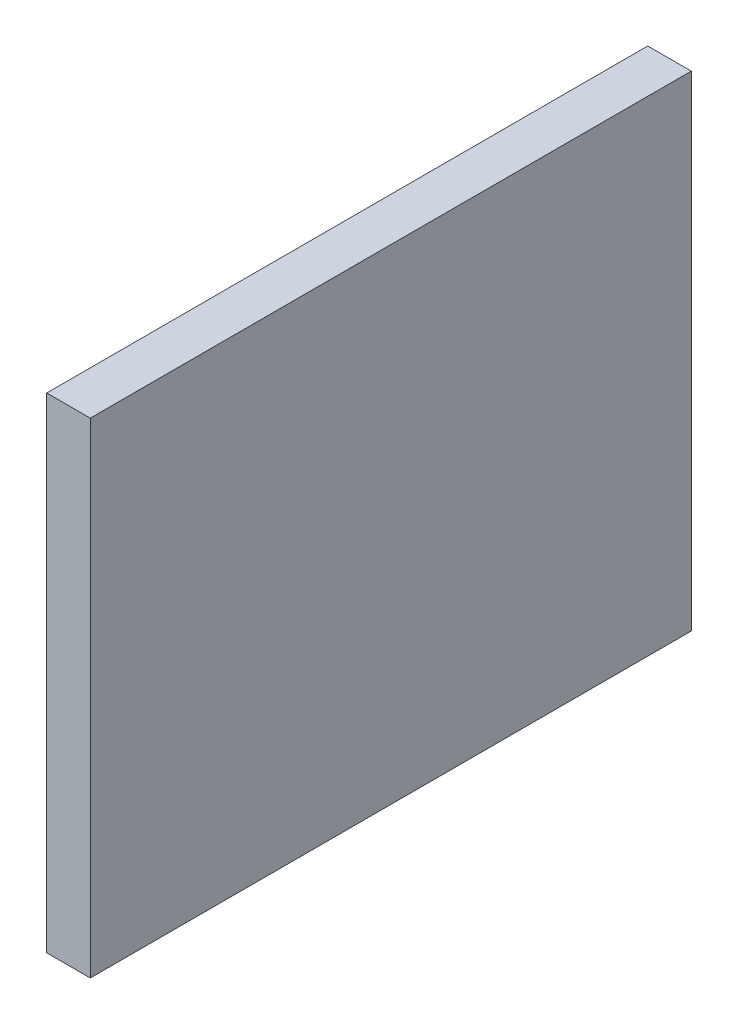
from build123d import *

# Parameters (mm, degrees)
CROQUIS1_W              = 41.4
CROQUIS1_H              = 33.400000005
SALIENTE_EXTRUIR1_DEPTH = 3


with BuildPart() as part:
    # Croquis1 → Saliente-Extruir1 (new body)
    with BuildSketch(Plane(origin=(0, 0, 0), x_dir=(0, 0, -1), z_dir=(1, 0, 0))):
        with Locations((3.314484047, -14.583729806)):
            Rectangle(CROQUIS1_W, CROQUIS1_H)
    extrude(amount=SALIENTE_EXTRUIR1_DEPTH)


solid = part.part
